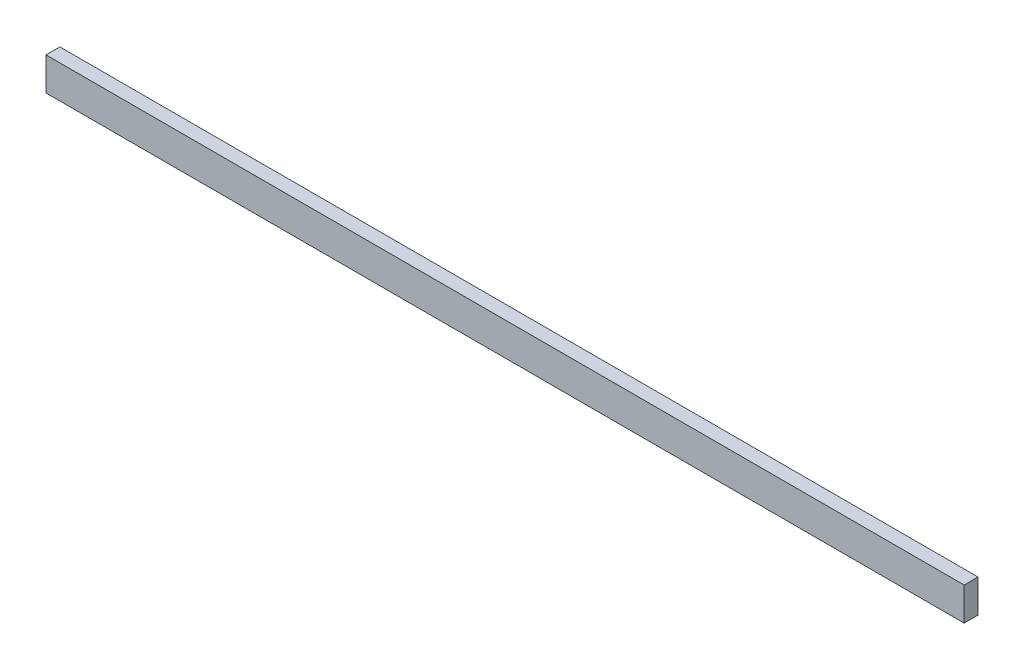
from build123d import *

# Parameters (mm, degrees)
SKETCH1_W           = 219.075
SKETCH1_H           = 7.874
BOSS_EXTRUDE1_DEPTH = 3.302


with BuildPart() as part:
    # Sketch1 → Boss-Extrude1 (new body)
    with BuildSketch(Plane.XY):
        with Locations((109.5375, 3.937)):
            Rectangle(SKETCH1_W, SKETCH1_H)
    extrude(amount=BOSS_EXTRUDE1_DEPTH)


solid = part.part
